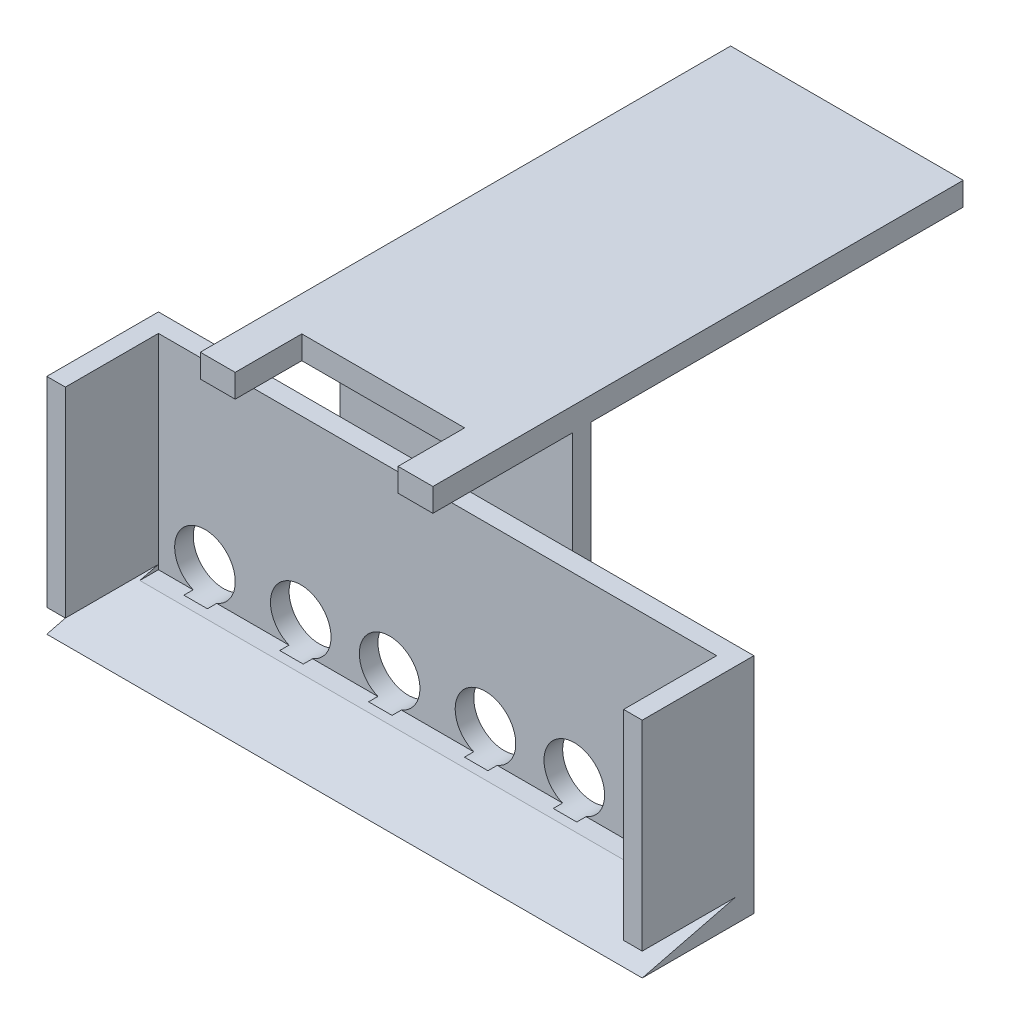
from build123d import *

# Parameters (mm, degrees)
SKETCH1_W               = 152.4
SKETCH1_H               = 25.4
BOSS_EXTRUDE1_DEPTH     = 5.08
BOSS_EXTRUDE2_DEPTH     = 5.08
SKETCH5_W               = 162.56
SKETCH5_H               = 60.96
BOSS_EXTRUDE3_DEPTH     = 5.08
CUT_EXTRUDE2_DEPTH      = 163.56
SKETCH7_W               = 63.5
SKETCH7_H               = 38.1
BOSS_EXTRUDE4_DEPTH     = 5.08
BOSS_EXTRUDE5_DEPTH     = 6.35
CUT_EXTRUDE3_REACH      = 97.25
SKETCH9_W               = 44.45
SKETCH9_H               = 39.033619981
SKETCH10_R              = 8.2696685
CUT_EXTRUDE4_DEPTH      = 2.54
CUT_EXTRUDE4_DEPTH_BACK = 112.76


with BuildPart() as part:
    # Sketch1 → Boss-Extrude1 (new body)
    with BuildSketch(Plane(origin=(0, 0, 0), x_dir=(1, 0, 0), z_dir=(0, 1, 0))):
        Rectangle(SKETCH1_W, SKETCH1_H)
    extrude(amount=BOSS_EXTRUDE1_DEPTH)

    # Sketch4 → Boss-Extrude2 (add)
    with BuildSketch(Plane(origin=(76.2, 0, 0), x_dir=(0, 0, -1), z_dir=(1, 0, 0))):
        Polygon((-12.7, 0), (-12.7, 5.08), (-12.7, 60.96), (12.7, 60.96), (12.7, 5.08), (12.7, 0), align=None)
    boss_extrude2 = extrude(amount=BOSS_EXTRUDE2_DEPTH)

    # Mirror1: Boss-Extrude2 across plane
    add(boss_extrude2.mirror(Plane(origin=(0, 0, 0), x_dir=(0, 0, 1), z_dir=(1, 0, 0))))

    # Sketch5 → Boss-Extrude3 (add)
    with BuildSketch(Plane(origin=(0, 0, -12.7), x_dir=(-1, 0, 0), z_dir=(0, 0, -1))):
        with Locations((0, 30.48)):
            Rectangle(SKETCH5_W, SKETCH5_H)
    extrude(amount=BOSS_EXTRUDE3_DEPTH)

    # Sketch6 → Cut-Extrude2 (cut, through all)
    with BuildSketch(Plane(origin=(81.28, 0, 0), x_dir=(0, 0, -1), z_dir=(1, 0, 0))):
        Polygon((-12.7, 0), (12.7, 6.35), (-12.7, 6.35), align=None)
    extrude(amount=-CUT_EXTRUDE2_DEPTH, mode=Mode.SUBTRACT)

    # Sketch7 → Boss-Extrude4 (add)
    with BuildSketch(Plane(origin=(0, 0, -17.78), x_dir=(-1, 0, 0), z_dir=(0, 0, -1))):
        with Locations((0, 69.85)):
            Rectangle(SKETCH7_W, SKETCH7_H)
    extrude(amount=BOSS_EXTRUDE4_DEPTH)

    # Sketch8 → Boss-Extrude5 (add)
    with BuildSketch(Plane(origin=(0, 88.9, 0), x_dir=(1, 0, 0), z_dir=(0, 1, 0))):
        Polygon((-31.75, 22.86), (-31.75, 124.46), (31.75, 124.46), (31.75, 22.86), (31.75, 17.78), (31.75, -20.32), (-31.75, -20.32), (-31.75, 17.78), align=None)
    extrude(amount=BOSS_EXTRUDE5_DEPTH)

    # Sketch9 → Cut-Extrude3 (cut, up to next)
    with BuildSketch(Plane(origin=(0, 95.25, 0), x_dir=(1, 0, 0), z_dir=(0, 1, 0)), mode=Mode.PRIVATE) as cut_extrude3_sk1:
        with Locations((0, -21.646832164)):
            Rectangle(SKETCH9_W, SKETCH9_H)
    cut_extrude3_tool1 = extrude(cut_extrude3_sk1.sketch, amount=-CUT_EXTRUDE3_REACH, mode=Mode.PRIVATE) & part.part
    add(cut_extrude3_tool1.solids().sort_by_distance((0, 95.25, 21.646832))[0], mode=Mode.SUBTRACT)

    # Sketch10 → Cut-Extrude4 (cut, two sides)
    with BuildSketch(Plane.XY.offset(-12.7)) as cut_extrude4_sk:
        with Locations((-13.081, 12.7)):
            Circle(SKETCH10_R)
        with Locations((13.081, 12.7)):
            Circle(SKETCH10_R)
        with Locations((37.338, 12.7)):
            Circle(SKETCH10_R)
        with Locations((63.5, 12.7)):
            Circle(SKETCH10_R)
        with Locations((-63.5, 12.7)):
            Circle(SKETCH10_R)
        with Locations((-37.338, 12.7)):
            Circle(SKETCH10_R)
    extrude(amount=CUT_EXTRUDE4_DEPTH, mode=Mode.SUBTRACT)
    extrude(cut_extrude4_sk.sketch, amount=-CUT_EXTRUDE4_DEPTH_BACK, mode=Mode.SUBTRACT)


solid = part.part
